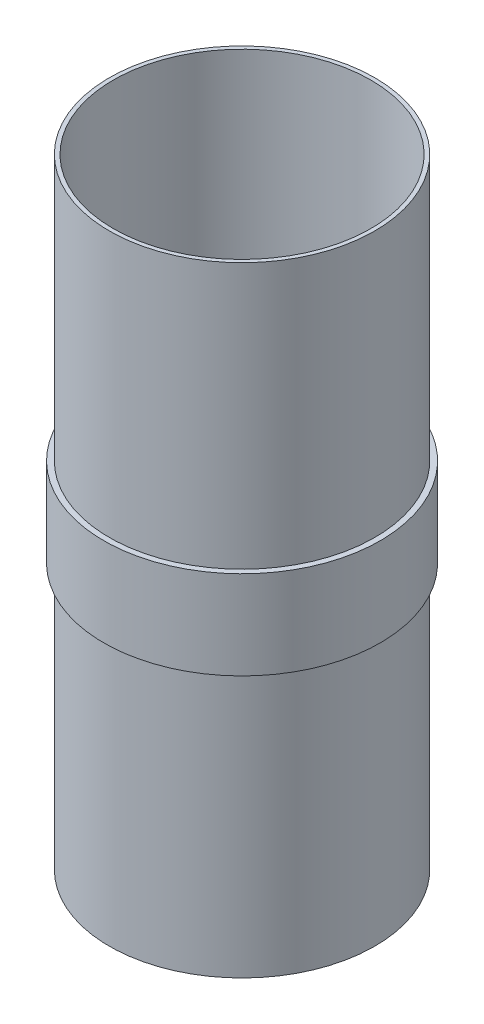
from build123d import *


with BuildPart() as part:
    # Sketch1 → Revolve1 (revolve)
    with BuildSketch(Plane.XY):
        Polygon((73.914, 0), (73.914, 355.6), (76.2, 355.6), (76.2, 203.2), (79.375, 203.2), (79.375, 152.4), (76.2, 152.4), (76.2, 0), align=None)
    revolve(axis=Axis((0, 0, 0), (0, 1, 0)))


solid = part.part
